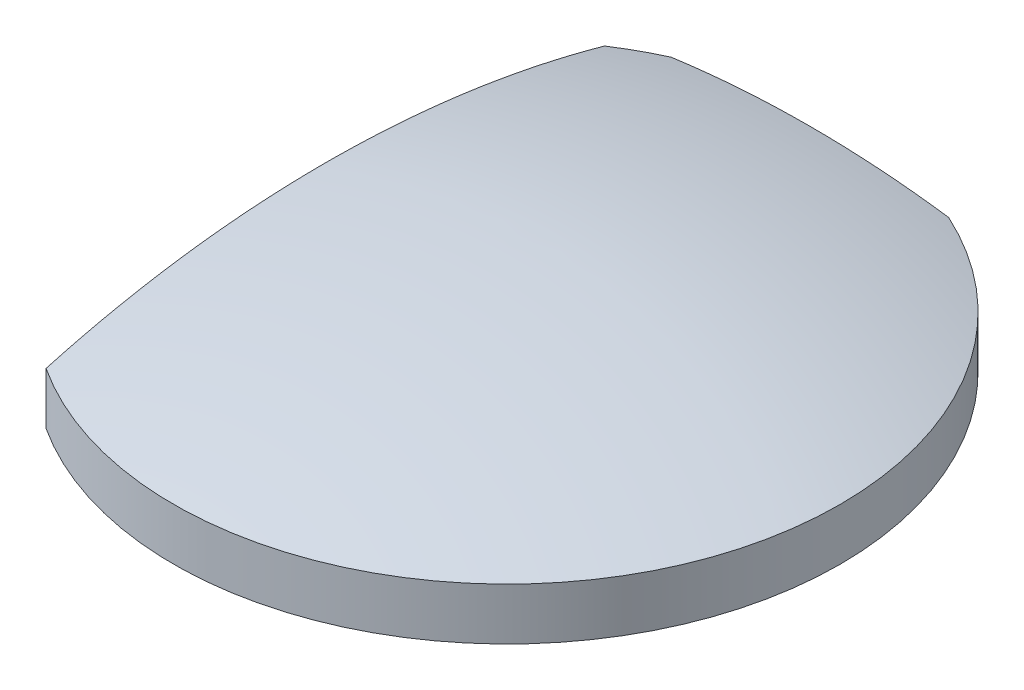
from build123d import *

# Parameters (mm, degrees)
CUT_EXTRUDE_1_DEPTH = 4.5


with BuildPart() as part:
    # Эскиз1 → Повернуть1 (revolve)
    with BuildSketch(Plane(origin=(0, 0, 0), x_dir=(0, 0, -1), z_dir=(1, 0, 0))):
        with BuildLine():
            Line((0, 0), (11, 0))
            Line((11, 0), (11, 1.713047493))
            ThreePointArc((11, 1.713047493), (5.572100126, 3.050352771), (0, 3.5))
            Line((0, 3.5), (0, 0))
        make_face()
    revolve(axis=Axis((0, 3.5, 0), (0, -1, 0)))

    # Эскиз2 → Вырез-Вытянуть1 (cut, through all)
    with BuildSketch(Plane.XZ):
        with BuildLine():
            ThreePointArc((-6, 9.219544457), (-11, 0), (-6, -9.219544457))
            Line((-6, -9.219544457), (-6, 9.219544457))
        make_face()
        with BuildLine():
            Line((4.582575695, -10), (-4.582575695, -10))
            ThreePointArc((-4.582575695, -10), (0, -11), (4.582575695, -10))
        make_face()
    extrude(amount=-CUT_EXTRUDE_1_DEPTH, mode=Mode.SUBTRACT)


solid = part.part
